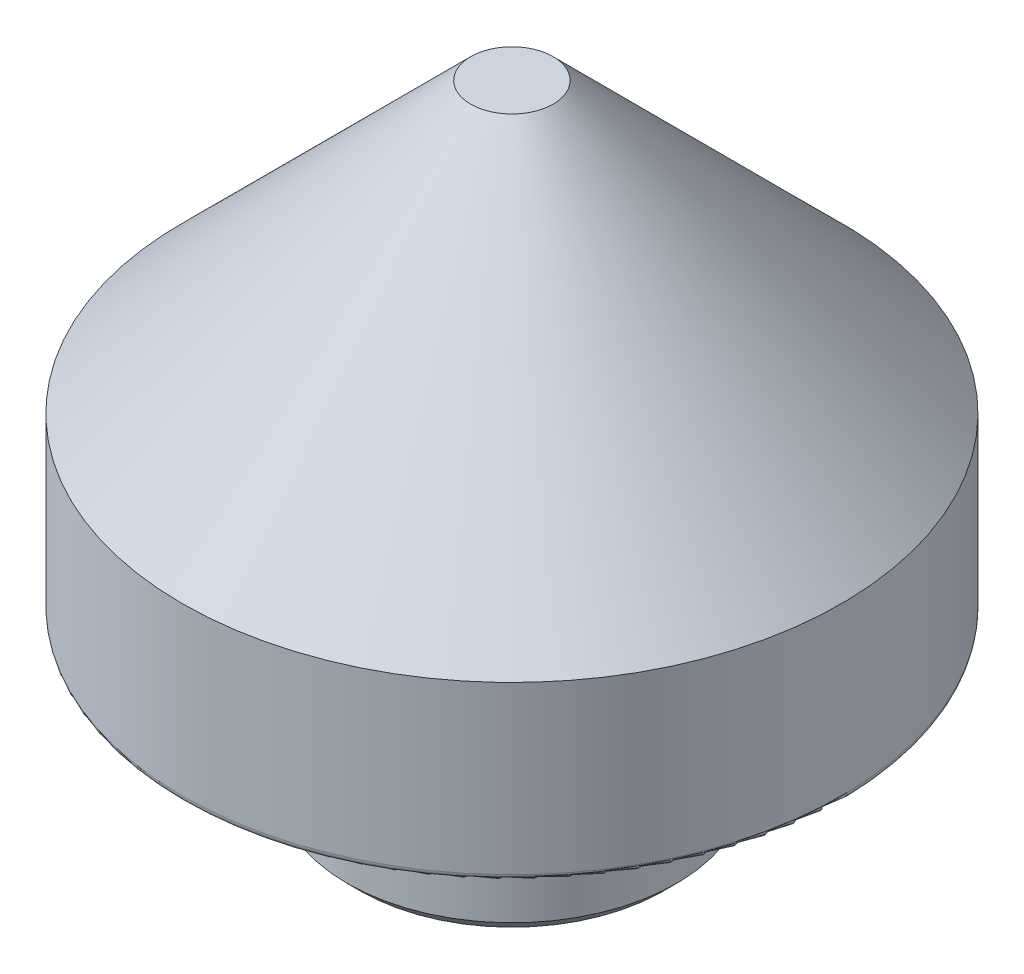
from build123d import *

# Parameters (mm, degrees)
SKETCH2_R                        = 0.762
CHAMFER1_SIZE                    = 0.508
FILLET1_R                        = 0.254
F_10_32_TAPPED_HOLE1_D           = 4.0386
F_10_32_TAPPED_HOLE1_DEPTH       = 10.3124
F_10_32_TAPPED_HOLE1_CSINK_D     = 4.826
F_10_32_TAPPED_HOLE1_CSINK_ANGLE = 90
F_10_32_TAPPED_HOLE1_TIP         = 1.213317848


with BuildPart() as part:
    # Sketch1 → Revolve1 (revolve)
    with BuildSketch(Plane.XY, mode=Mode.PRIVATE) as revolve1_sk:
        Polygon((12.7, 0), (6.35, 0), (6.35, -6.35), (0, -6.35), (0, 17.78), (1.5875, 17.78), (12.7, 6.6675), align=None)
    revolve(revolve1_sk.sketch.rotate(Axis((0, 35.289344262, 0), (0, -1, 0)), 90), axis=Axis((0, 35.289344262, 0), (0, -1, 0)))  # turned: the seam where the file's is

    # Sketch2 → Cut-Revolve1 (revolve, cut)
    with BuildSketch(Plane.XY, mode=Mode.PRIVATE) as cut_revolve1_sk:
        with Locations((6.858, -0.508)):
            Circle(SKETCH2_R)
    revolve(cut_revolve1_sk.sketch.rotate(Axis((0, 0, 0), (0, -1, 0)), 90), axis=Axis((0, 0, 0), (0, -1, 0)), mode=Mode.SUBTRACT)  # turned: the seam where the file's is

    # Chamfer1
    chamfer1_edges = [part.edges().sort_by_distance(p)[0] for p in [
        (0, -6.35, -6.35),
    ]]
    chamfer(chamfer1_edges, length=CHAMFER1_SIZE)

    # Fillet1
    fillet1_edges = [part.edges().sort_by_distance(p)[0] for p in [
        (0, 0, -12.7),
    ]]
    fillet(fillet1_edges, radius=FILLET1_R)

    # 10-32 Tapped Hole1
    with Locations(Plane.XZ.offset(6.35)):
        with Locations((0, 0)):
            CounterSinkHole(F_10_32_TAPPED_HOLE1_D / 2, F_10_32_TAPPED_HOLE1_CSINK_D / 2, depth=F_10_32_TAPPED_HOLE1_DEPTH, counter_sink_angle=F_10_32_TAPPED_HOLE1_CSINK_ANGLE)
            with Locations((0, 0, -(F_10_32_TAPPED_HOLE1_DEPTH + F_10_32_TAPPED_HOLE1_TIP / 2))):  # 118° drill point
                Cone(0, F_10_32_TAPPED_HOLE1_D / 2, F_10_32_TAPPED_HOLE1_TIP, mode=Mode.SUBTRACT)


solid = part.part
